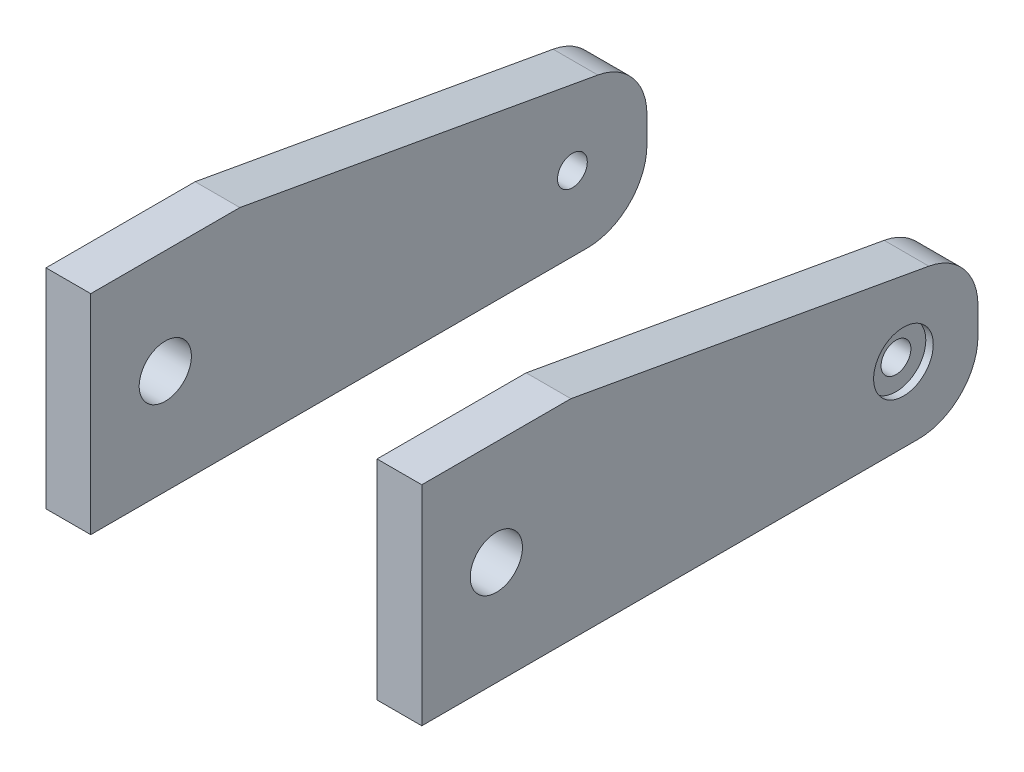
from build123d import *

# Parameters (mm, degrees)
SKETCH2_R           = 1
SKETCH2_R_2         = 1.75
BOSS_EXTRUDE1_DEPTH = 3
SKETCH3_R           = 2
CUT_EXTRUDE1_DEPTH  = 0.5


with BuildPart() as part:
    # Sketch2 → Boss-Extrude1 (new body)
    with BuildSketch(Plane(origin=(9.6, 0, 0), x_dir=(0, 0, -1), z_dir=(1, 0, 0))):
        with BuildLine():
            Line((-22.323377708, -11), (0.976622292, -11))
            ThreePointArc((0.976622292, -11), (3.805049417, -9.828427125), (4.976622292, -7))
            Line((4.976622292, -7), (4.976622292, -5.243211535))
            ThreePointArc((4.976622292, -5.243211535), (4.044591546, -2.676586386), (1.682839964, -1.306048013))
            Line((1.682839964, -1.306048013), (-22.323377708, 3))
            Line((-22.323377708, 3), (-32.323377708, 3))
            Line((-32.323377708, 3), (-32.323377708, -11))
            Line((-32.323377708, -11), (-22.323377708, -11))
        make_face()
        with Locations((-0.023377708, -6)):
            Circle(SKETCH2_R, mode=Mode.SUBTRACT)
        with Locations((-27.323377708, -4)):
            Circle(SKETCH2_R_2, mode=Mode.SUBTRACT)
    extrude(amount=BOSS_EXTRUDE1_DEPTH)

    # Sketch3 → Cut-Extrude1 (cut)
    with BuildSketch(Plane(origin=(12.6, 0, 0), x_dir=(0, 0, -1), z_dir=(1, 0, 0))):
        with Locations((-0.023377708, -6)):
            Circle(SKETCH3_R)
    extrude(amount=-CUT_EXTRUDE1_DEPTH, mode=Mode.SUBTRACT)


with BuildPart() as body_2:
    # Mirror4: mirrored copy
    add(part.part.mirror(Plane(origin=(0, 0, 0), x_dir=(0, 0, 1), z_dir=(1, 0, 0))))


solid = Compound([part.part, body_2.part])
